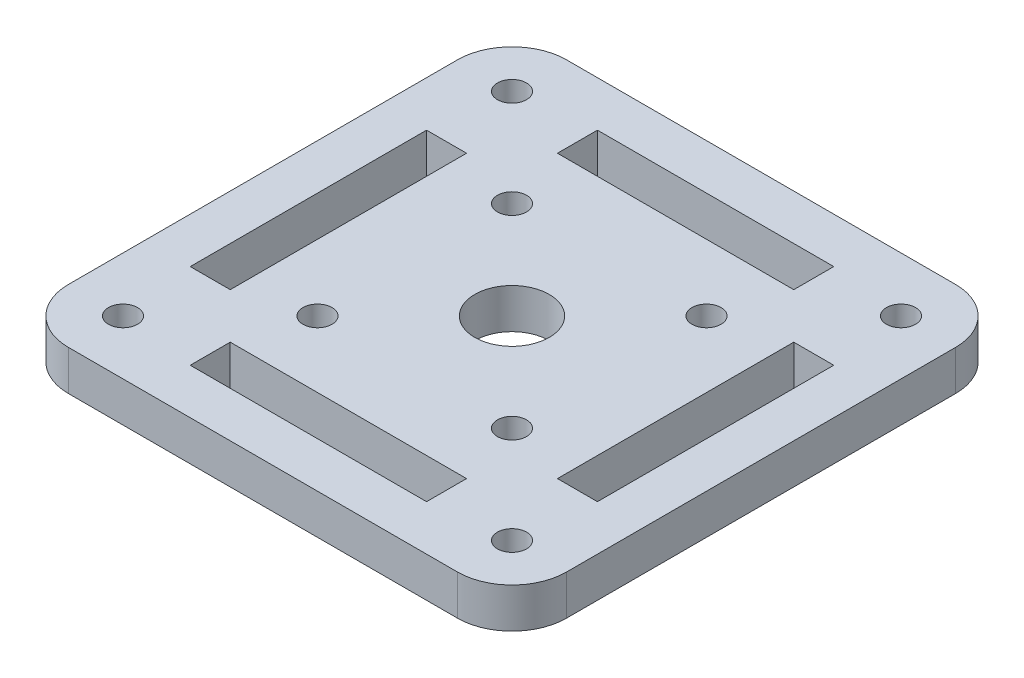
from build123d import *

# Parameters (mm, degrees)
SKETCH_1_W          = 54.8
SKETCH_1_H          = 54.8
SKETCH_1_R          = 4.1
SKETCH_1_R_2        = 1.6
EXTRUDE_1_DEPTH     = 4.4
FILLET_1_R          = 6
SKETCH_2_R          = 1.6
CUT_EXTRUDE_1_DEPTH = 10


with BuildPart() as part:
    # 草图1 → 凸台-拉伸1 (new body)
    with BuildSketch(Plane(origin=(0, 0, 0), x_dir=(1, 0, 0), z_dir=(0, 1, 0))):
        Rectangle(SKETCH_1_W, SKETCH_1_H)
        Circle(SKETCH_1_R, mode=Mode.SUBTRACT)
        with Locations((21.4, 21.4)):
            Circle(SKETCH_1_R_2, mode=Mode.SUBTRACT)
        with Locations((21.4, -21.4)):
            Circle(SKETCH_1_R_2, mode=Mode.SUBTRACT)
        with Locations((-21.4, -21.4)):
            Circle(SKETCH_1_R_2, mode=Mode.SUBTRACT)
        with Locations((-21.4, 21.4)):
            Circle(SKETCH_1_R_2, mode=Mode.SUBTRACT)
        Polygon((18, -5), (18, 5), (18, 13), (22.4, 13), (22.4, 5), (22.4, -5), (22.4, -13), (18, -13), align=None, mode=Mode.SUBTRACT)
        Polygon((-5, 18), (-13, 18), (-13, 22.4), (-5, 22.4), (5, 22.4), (13, 22.4), (13, 18), (5, 18), align=None, mode=Mode.SUBTRACT)
        Polygon((5, -18), (13, -18), (13, -22.4), (5, -22.4), (-5, -22.4), (-13, -22.4), (-13, -18), (-5, -18), align=None, mode=Mode.SUBTRACT)
        Polygon((-18, 5), (-18, -5), (-18, -13), (-22.4, -13), (-22.4, -5), (-22.4, 5), (-22.4, 13), (-18, 13), align=None, mode=Mode.SUBTRACT)
    extrude(amount=EXTRUDE_1_DEPTH)

    # 圆角1
    fillet_1_edges = [part.edges().sort_by_distance(p)[0] for p in [
        (27.4, 2.2, 27.4),
        (-27.4, 2.2, 27.4),
        (-27.4, 2.2, -27.4),
        (27.4, 2.2, -27.4),
    ]]
    fillet(fillet_1_edges, radius=FILLET_1_R)

    # 草图2 → 切除-拉伸1 (cut)
    with BuildSketch(Plane(origin=(0, 4.4, 0), x_dir=(1, 0, 0), z_dir=(0, 1, 0))):
        with Locations((10.7, 10.7)):
            Circle(SKETCH_2_R)
        with Locations((10.7, -10.7)):
            Circle(SKETCH_2_R)
        with Locations((-10.7, -10.7)):
            Circle(SKETCH_2_R)
        with Locations((-10.7, 10.7)):
            Circle(SKETCH_2_R)
    extrude(amount=-CUT_EXTRUDE_1_DEPTH, mode=Mode.SUBTRACT)


solid = part.part
